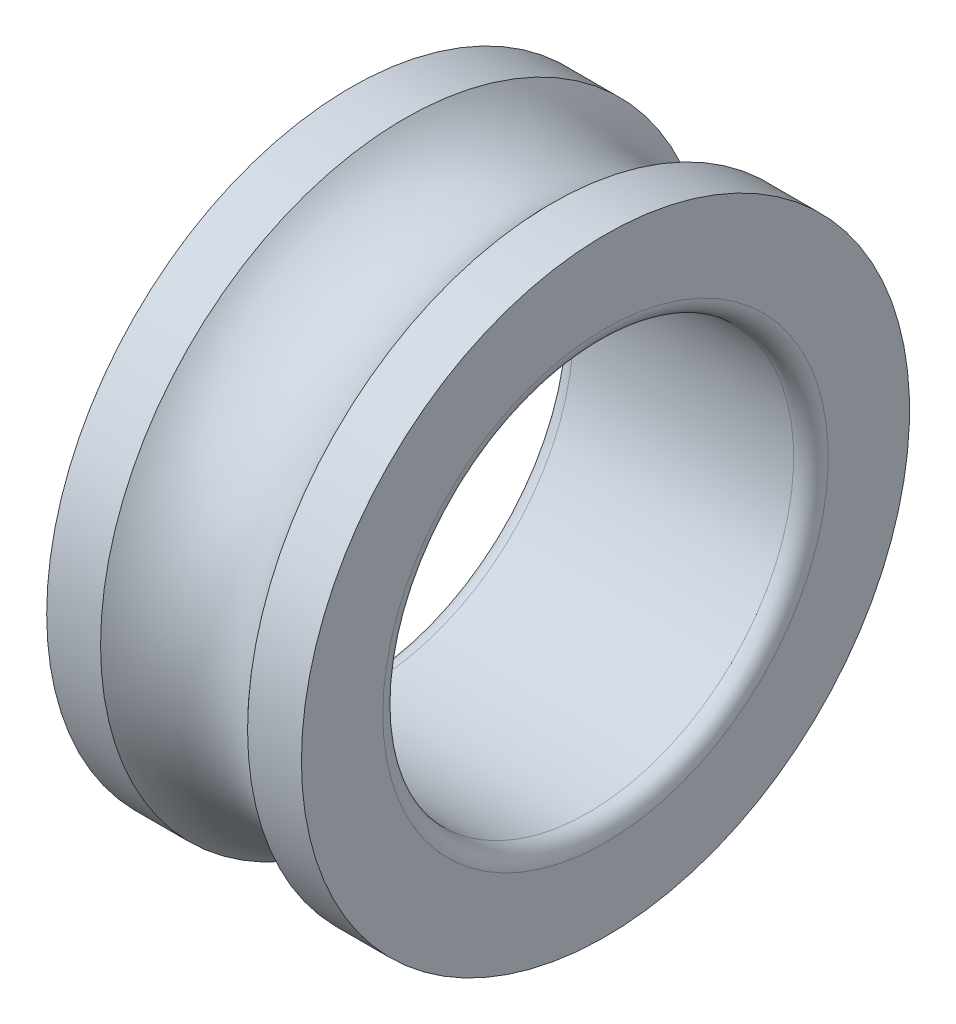
from build123d import *

# Parameters (mm, degrees)
FILLET1_R = 2.1


with BuildPart() as part:
    # Sketch1 → Revolve1 (revolve)
    with BuildSketch(Plane.XY):
        with BuildLine():
            Line((-15.5, 37), (-8.94427191, 37))
            ThreePointArc((-8.94427191, 37), (0, 33), (8.94427191, 37))
            Line((8.94427191, 37), (15.5, 37))
            Line((15.5, 37), (15.5, 25))
            Line((15.5, 25), (-15.5, 25))
            Line((-15.5, 25), (-15.5, 37))
        make_face()
    revolve(axis=Axis((0, 0, 0), (1, 0, 0)))

    # Fillet1
    fillet1_edges = [part.edges().sort_by_distance(p)[0] for p in [
        (15.5, -25, 0),
        (-15.5, -25, 0),
    ]]
    fillet(fillet1_edges, radius=FILLET1_R)


solid = part.part
